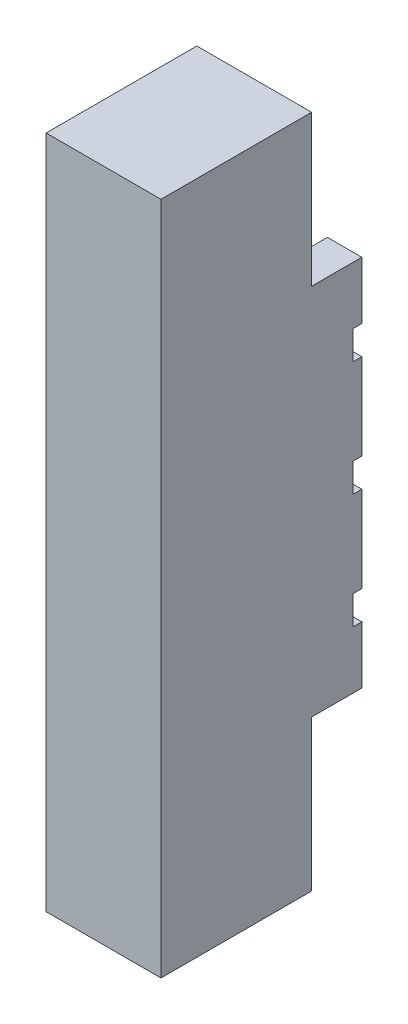
from build123d import *

# Parameters (mm, degrees)
BOSS_EXTRUDE1_DEPTH   = 130
SKETCH2_W             = 40
SKETCH2_H             = 10
CUT_EXTRUDE1_DEPTH    = 3
M3_TAPPED_HOLE1_D     = 2.5
M3_TAPPED_HOLE1_DEPTH = 8
M3_TAPPED_HOLE1_TIP   = 0.751075774
M3_TAPPED_HOLE2_D     = 2.5
M3_TAPPED_HOLE2_DEPTH = 8
M3_TAPPED_HOLE2_TIP   = 0.751075774
SKETCH9_W             = 52.5
SKETCH9_H             = 52.5
BOSS_EXTRUDE2_DEPTH   = 40


with BuildPart() as part:
    # Sketch1 → Boss-Extrude1 (new body)
    with BuildSketch(Plane(origin=(0, 0, 0), x_dir=(1, 0, 0), z_dir=(0, 1, 0))):
        Polygon((-20, 35), (-20, -35), (20, -35), (20, 35), (8, 35), (8, 27.5), (-8, 27.5), (-8, 35), align=None)
    extrude(amount=BOSS_EXTRUDE1_DEPTH)

    # Sketch2 → Cut-Extrude1 (cut)
    with BuildSketch(Plane(origin=(0, 0, -35), x_dir=(-1, 0, 0), z_dir=(0, 0, -1))):
        with Locations((0, 25)):
            Rectangle(SKETCH2_W, SKETCH2_H)
        with Locations((0, 65)):
            Rectangle(SKETCH2_W, SKETCH2_H)
        with Locations((0, 105)):
            Rectangle(SKETCH2_W, SKETCH2_H)
    extrude(amount=-CUT_EXTRUDE1_DEPTH, mode=Mode.SUBTRACT)

    # M3 Tapped Hole1
    with Locations(Plane(origin=(-14, 25, -32), x_dir=(-1, 0, 0), z_dir=(0, 0, -1))):
        with Locations((0, 0), (-28, 0), (0, 80), (-28, 80), (0, 40), (-28, 40)):
            Hole(M3_TAPPED_HOLE1_D / 2, depth=M3_TAPPED_HOLE1_DEPTH)
            with Locations((0, 0, -(M3_TAPPED_HOLE1_DEPTH + M3_TAPPED_HOLE1_TIP / 2))):  # 118° drill point
                Cone(0, M3_TAPPED_HOLE1_D / 2, M3_TAPPED_HOLE1_TIP, mode=Mode.SUBTRACT)

    # M3 Tapped Hole2
    with Locations(Plane(origin=(0, 25, -27.5), x_dir=(-1, 0, 0), z_dir=(0, 0, -1))):
        with Locations((0, 0), (0, 40), (0, 80)):
            Hole(M3_TAPPED_HOLE2_D / 2, depth=M3_TAPPED_HOLE2_DEPTH)
            with Locations((0, 0, -(M3_TAPPED_HOLE2_DEPTH + M3_TAPPED_HOLE2_TIP / 2))):  # 118° drill point
                Cone(0, M3_TAPPED_HOLE2_D / 2, M3_TAPPED_HOLE2_TIP, mode=Mode.SUBTRACT)

    # Sketch9 → Boss-Extrude2 (add)
    with BuildSketch(Plane.ZY.offset(20)):
        with Locations((8.75, -26.25)):
            Rectangle(SKETCH9_W, SKETCH9_H)
        with Locations((8.75, 156.25)):
            Rectangle(SKETCH9_W, SKETCH9_H)
    extrude(amount=-BOSS_EXTRUDE2_DEPTH)


solid = part.part
